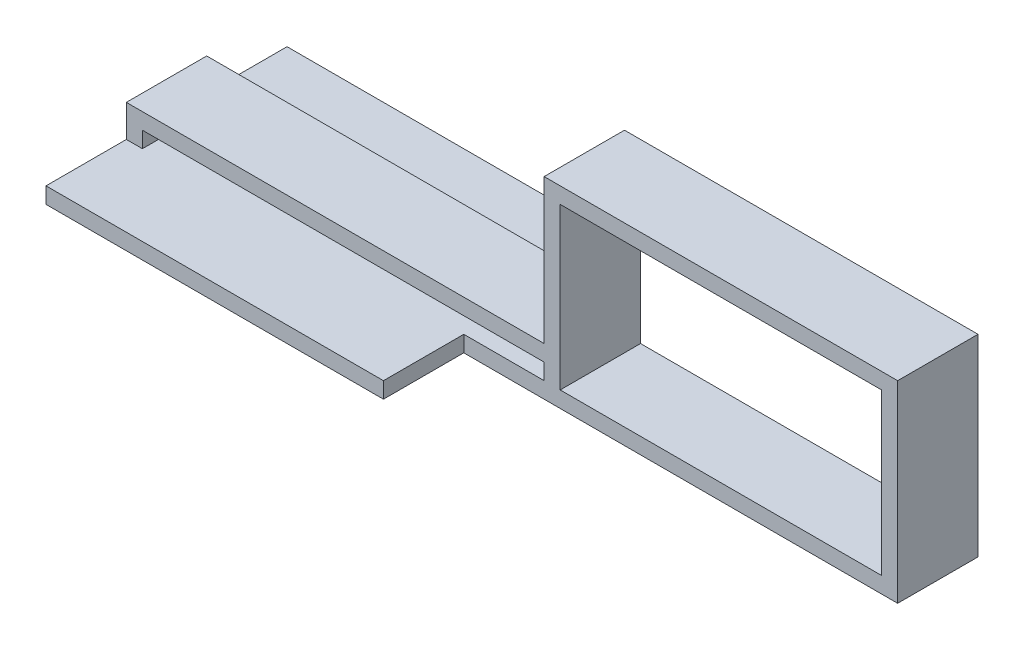
from build123d import *

# Parameters (mm, degrees)
EXTRUDE_1_DEPTH      = 5
EXTRUDE_1_DEPTH_BACK = 5
SKETCH_1_W           = 50
SKETCH_1_H           = 2
SKETCH_1_W_2         = 40
SKETCH_1_H_2         = 20
EXTRUDE_2_DEPTH      = 10
EXTRUDE_2_DEPTH_BACK = 20


with BuildPart() as part:
    # 草图1 → 凸台-拉伸1 (new, two sides: drawn at the far end of the back side and taken through both)
    with BuildSketch(Plane.XY.offset(-EXTRUDE_1_DEPTH_BACK)):
        Polygon((-74.170588235, -24.287254902), (-22.170588235, -24.287254902), (21.829411765, -24.287254902), (21.829411765, -0.287254902), (-22.170588235, -0.287254902), (-22.170588235, -18.287254902), (-74.170588235, -18.287254902), (-74.170588235, -22.287254902), align=None)
        with Locations((-47.170588235, -21.287254902)):
            Rectangle(SKETCH_1_W, SKETCH_1_H, mode=Mode.SUBTRACT)
        with Locations((-0.170588235, -12.287254902)):
            Rectangle(SKETCH_1_W_2, SKETCH_1_H_2, mode=Mode.SUBTRACT)
    extrude(amount=EXTRUDE_1_DEPTH + EXTRUDE_1_DEPTH_BACK)

    # 草图2 → 凸台-拉伸2 (add, two sides: drawn at the far end of the back side and taken through both)
    with BuildSketch(Plane.XY.offset(5).offset(-EXTRUDE_2_DEPTH_BACK)):
        Polygon((-74.170588235, -24.287254902), (-32.170588235, -24.287254902), (-32.170588235, -22.287254902), (-72.170588235, -22.287254902), (-74.170588235, -22.287254902), align=None)
    extrude(amount=EXTRUDE_2_DEPTH + EXTRUDE_2_DEPTH_BACK)


solid = part.part
